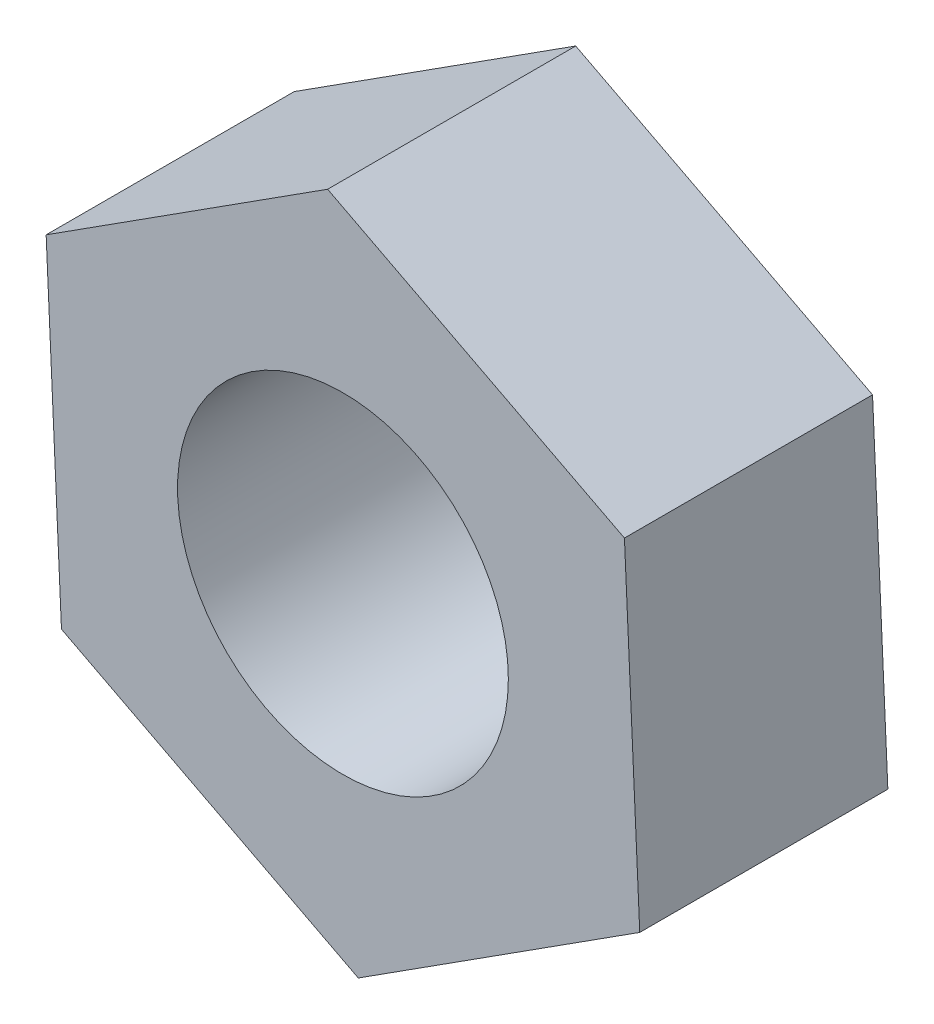
from build123d import *

# Parameters (mm, degrees)
SKETCH_1_R      = 2
EXTRUDE_1_DEPTH = 3


with BuildPart() as part:
    # 草图1 → 凸台-拉伸1 (new body)
    with BuildSketch(Plane.XY):
        Polygon((3.588972267, -1.858120394), (3.403665598, 2.17908096), (-0.185306669, 4.037201354), (-3.588972267, 1.858120394), (-3.403665598, -2.17908096), (0.185306669, -4.037201354), align=None)
        Circle(SKETCH_1_R, mode=Mode.SUBTRACT)
    extrude(amount=EXTRUDE_1_DEPTH)


solid = part.part
